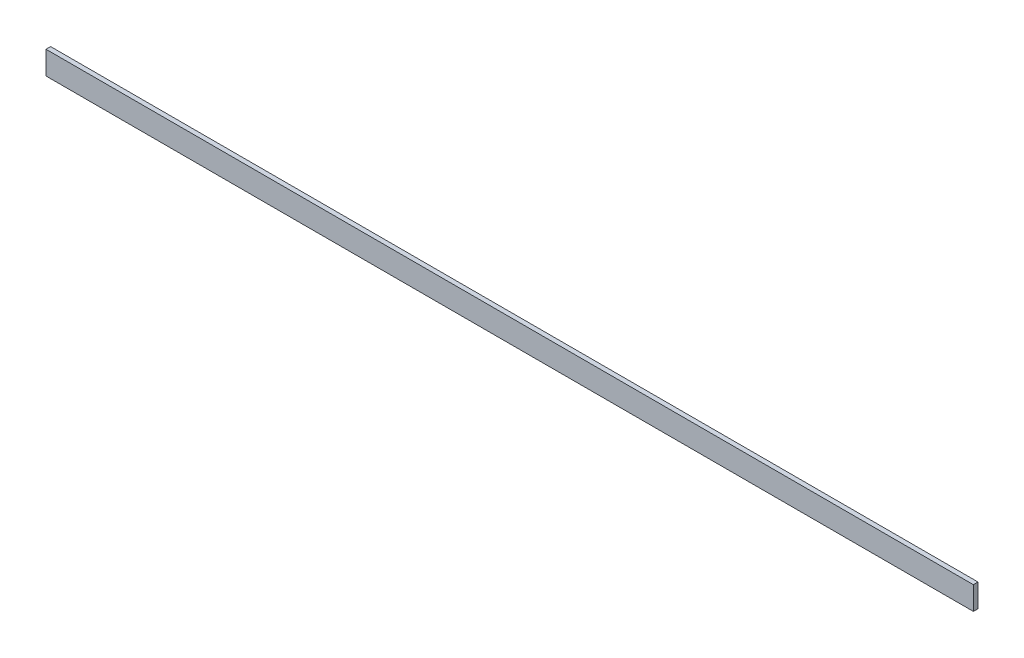
from build123d import *

# Parameters (mm, degrees)
SKETCH2_W           = 600
SKETCH2_H           = 15
BOSS_EXTRUDE1_DEPTH = 3


with BuildPart() as part:
    # Sketch2 → Boss-Extrude1 (new body)
    with BuildSketch(Plane.XY):
        with Locations((300, 7.5)):
            Rectangle(SKETCH2_W, SKETCH2_H)
    extrude(amount=BOSS_EXTRUDE1_DEPTH)


solid = part.part
